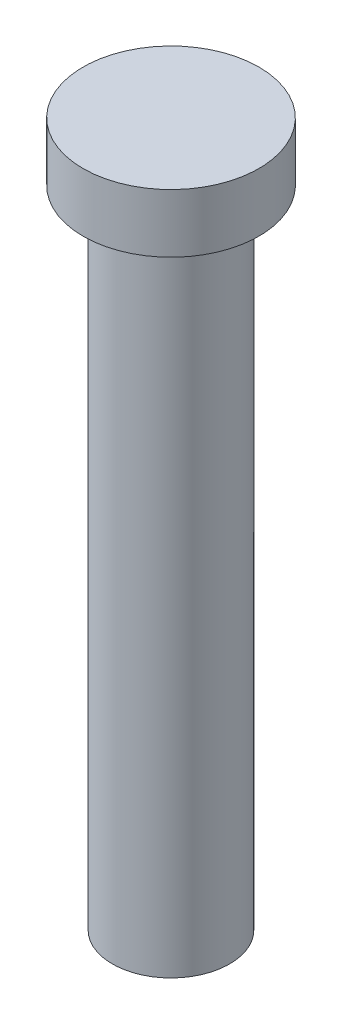
from build123d import *

# Parameters (mm, degrees)
SKETCH1_R           = 15
BOSS_EXTRUDE1_DEPTH = 10
SKETCH2_R           = 10
BOSS_EXTRUDE2_DEPTH = 110


with BuildPart() as part:
    # Sketch1 → Boss-Extrude1 (new body)
    with BuildSketch(Plane(origin=(0, 0, 0), x_dir=(1, 0, 0), z_dir=(0, 1, 0))):
        Circle(SKETCH1_R)
    extrude(amount=BOSS_EXTRUDE1_DEPTH)

    # Sketch2 → Boss-Extrude2 (add)
    with BuildSketch(Plane.XZ):
        Circle(SKETCH2_R)
    extrude(amount=BOSS_EXTRUDE2_DEPTH)


solid = part.part
